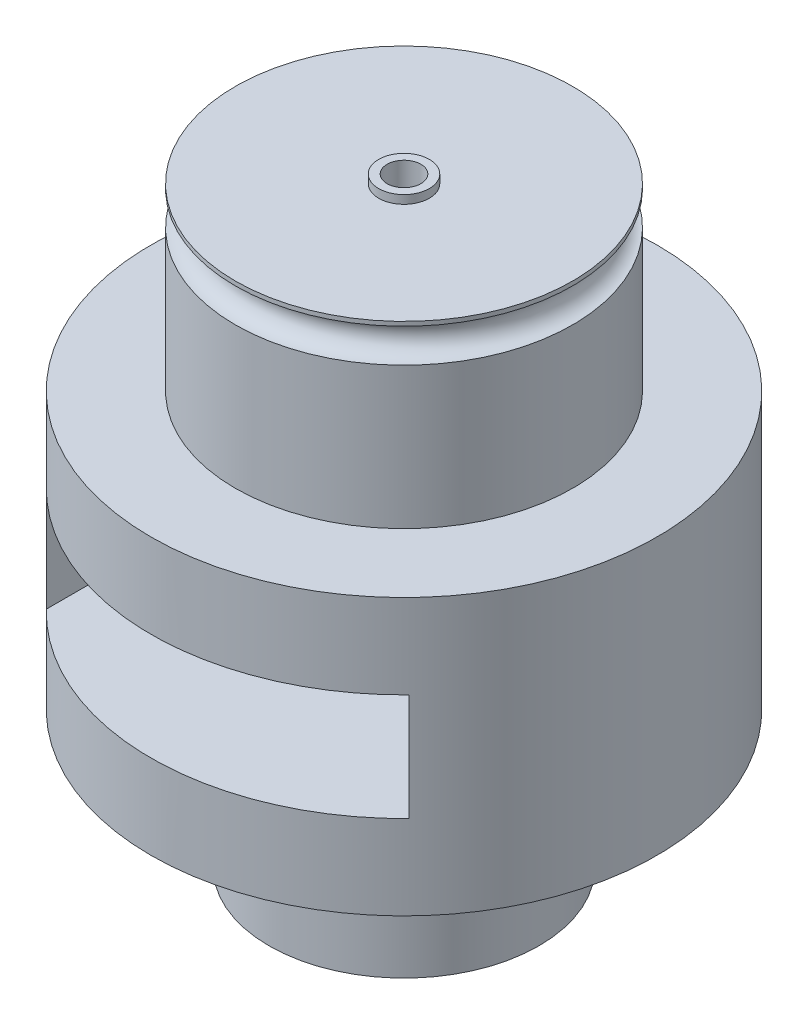
from build123d import *

# Parameters (mm, degrees)
SKETCH1_R               = 15
SKETCH1_R_2             = 1
BOSS_EXTRUDE1_DEPTH     = 32.6375
SKETCH2_W               = 21.5
SKETCH2_H               = 6.35
CUT_EXTRUDE1_DEPTH      = 16
CUT_EXTRUDE1_DEPTH_BACK = 16
SKETCH3_R               = 1.5
SKETCH3_R_2             = 1
BOSS_EXTRUDE2_DEPTH     = 0.5
SKETCH4_R               = 10
SKETCH4_R_2             = 1
BOSS_EXTRUDE3_DEPTH     = 2.5
CUT_SWEEP2_PROFILE_R    = 1
SKETCH82_R              = 1.5
SKETCH82_R_2            = 1
BOSS_EXTRUDE5_DEPTH     = 0.5
SKETCH91_R              = 15
SKETCH91_R_2            = 8
CUT_EXTRUDE2_DEPTH      = 1.5
CUT_EXTRUDE2_DEPTH_BACK = 8.14375
SKETCH92_R              = 15
SKETCH92_R_2            = 10
CUT_EXTRUDE3_DEPTH      = 8.14375


with BuildPart() as part:
    # Sketch1 → Boss-Extrude1 (new body)
    with BuildSketch(Plane(origin=(0, 0, 0), x_dir=(1, 0, 0), z_dir=(0, 1, 0))):
        Circle(SKETCH1_R)
        Circle(SKETCH1_R_2, mode=Mode.SUBTRACT)
    extrude(amount=BOSS_EXTRUDE1_DEPTH)

    # Sketch2 → Cut-Extrude1 (cut, two sides)
    with BuildSketch(Plane.XY) as cut_extrude1_sk:
        with Locations((0, 16.31875)):
            Rectangle(SKETCH2_W, SKETCH2_H)
    extrude(amount=CUT_EXTRUDE1_DEPTH, mode=Mode.SUBTRACT)
    extrude(cut_extrude1_sk.sketch, amount=-CUT_EXTRUDE1_DEPTH_BACK, mode=Mode.SUBTRACT)

    # Sketch3 → Boss-Extrude2 (add)
    with BuildSketch(Plane(origin=(0, 0, 0), x_dir=(-1, 0, 0), z_dir=(0, -1, 0))):
        Circle(SKETCH3_R)
        Circle(SKETCH3_R_2, mode=Mode.SUBTRACT)
    extrude(amount=BOSS_EXTRUDE2_DEPTH)

    # Sketch4 → Boss-Extrude3 (add)
    with BuildSketch(Plane(origin=(0, 32.6375, 0), x_dir=(1, 0, 0), z_dir=(0, 1, 0))):
        Circle(SKETCH4_R)
        Circle(SKETCH4_R_2, mode=Mode.SUBTRACT)
    extrude(amount=BOSS_EXTRUDE3_DEPTH)

    # Cut-Sweep2: sweep along a path in Sketch77
    with BuildLine(Plane(origin=(0, 33.8875, 0), x_dir=(1, 0, 0), z_dir=(0, 1, 0))) as cut_sweep2_path:
        CenterArc((0, 0), 10, 0, 360)
    # Cut-Sweep2 profile (on start of the path) → Cut-Sweep2 (sweep, cut)
    with BuildSketch(Plane(origin=(10, 33.8875, 0), x_dir=(-1, 0, 0), z_dir=(0, 0, -1))):
        Circle(CUT_SWEEP2_PROFILE_R)
    sweep(path=cut_sweep2_path.line, mode=Mode.SUBTRACT)

    # Sketch82 → Boss-Extrude5 (add)
    with BuildSketch(Plane(origin=(0, 35.1375, 0), x_dir=(1, 0, 0), z_dir=(0, 1, 0))):
        Circle(SKETCH82_R)
        Circle(SKETCH82_R_2, mode=Mode.SUBTRACT)
    extrude(amount=BOSS_EXTRUDE5_DEPTH)

    # Sketch91 → Cut-Extrude2 (cut, two sides)
    with BuildSketch(Plane.XZ) as cut_extrude2_sk:
        Circle(SKETCH91_R)
        Circle(SKETCH91_R_2, mode=Mode.SUBTRACT)
    extrude(amount=CUT_EXTRUDE2_DEPTH, mode=Mode.SUBTRACT)
    extrude(cut_extrude2_sk.sketch, amount=-CUT_EXTRUDE2_DEPTH_BACK, mode=Mode.SUBTRACT)

    # Sketch92 → Cut-Extrude3 (cut)
    with BuildSketch(Plane(origin=(0, 32.6375, 0), x_dir=(1, 0, 0), z_dir=(0, 1, 0))):
        Circle(SKETCH92_R)
        Circle(SKETCH92_R_2, mode=Mode.SUBTRACT)
    extrude(amount=-CUT_EXTRUDE3_DEPTH, mode=Mode.SUBTRACT)


solid = part.part
